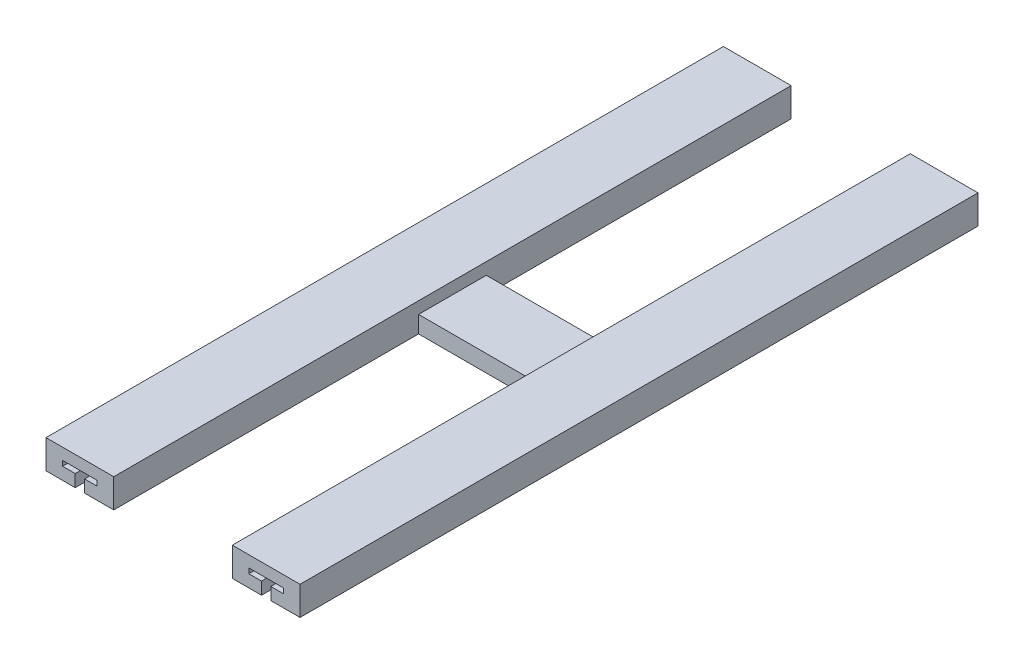
from build123d import *

# Parameters (mm, degrees)
BOSS_EXTRUDE1_DEPTH     = 17
SKETCH2_W               = 70
SKETCH2_H               = 40
CUT_EXTRUDE1_DEPTH      = 7
CUT_EXTRUDE2_DEPTH      = 401.331856029
SKETCH4_W               = 150
SKETCH4_H               = 39.668143971
CUT_EXTRUDE3_DEPTH      = 1
CUT_EXTRUDE3_DEPTH_BACK = 18


with BuildPart() as part:
    # Sketch1 → Boss-Extrude1 (new body)
    with BuildSketch(Plane(origin=(0, 0, 0), x_dir=(1, 0, 0), z_dir=(0, 1, 0))):
        Polygon((40, 449.668143971), (40, 269.668143971), (110, 269.668143971), (110, 450), (150, 450), (150, 10), (110, 10), (110, 229.668143971), (40, 229.668143971), (40, 49.668143971), (0, 49.668143971), (0, 449.668143971), align=None)
    extrude(amount=BOSS_EXTRUDE1_DEPTH)

    # Sketch2 → Cut-Extrude1 (cut)
    with BuildSketch(Plane(origin=(0, 17, 0), x_dir=(1, 0, 0), z_dir=(0, 1, 0))):
        with Locations((75, 249.668143971)):
            Rectangle(SKETCH2_W, SKETCH2_H)
    extrude(amount=-CUT_EXTRUDE1_DEPTH, mode=Mode.SUBTRACT)

    # Sketch3 → Cut-Extrude2 (cut, through all)
    with BuildSketch(Plane.XY.offset(-49.668143971)):
        Polygon((17.25, 0), (17.25, 7.25), (9.75, 7.25), (9.75, 10.25), (30.25, 10.25), (30.25, 7.25), (22.75, 7.25), (22.75, 0), align=None)
    cut_extrude2 = extrude(amount=-CUT_EXTRUDE2_DEPTH, mode=Mode.SUBTRACT)

    # Mirror1: Cut-Extrude2 across plane
    add(cut_extrude2.mirror(Plane(origin=(75, 0, 0), x_dir=(0, 0, 1), z_dir=(1, 0, 0))), mode=Mode.SUBTRACT)

    # Sketch4 → Cut-Extrude3 (cut, two sides)
    with BuildSketch(Plane(origin=(0, 17, 0), x_dir=(1, 0, 0), z_dir=(0, 1, 0))) as cut_extrude3_sk:
        with Locations((75, 29.834071986)):
            Rectangle(SKETCH4_W, SKETCH4_H)
    extrude(amount=CUT_EXTRUDE3_DEPTH, mode=Mode.SUBTRACT)
    extrude(cut_extrude3_sk.sketch, amount=-CUT_EXTRUDE3_DEPTH_BACK, mode=Mode.SUBTRACT)


solid = part.part
